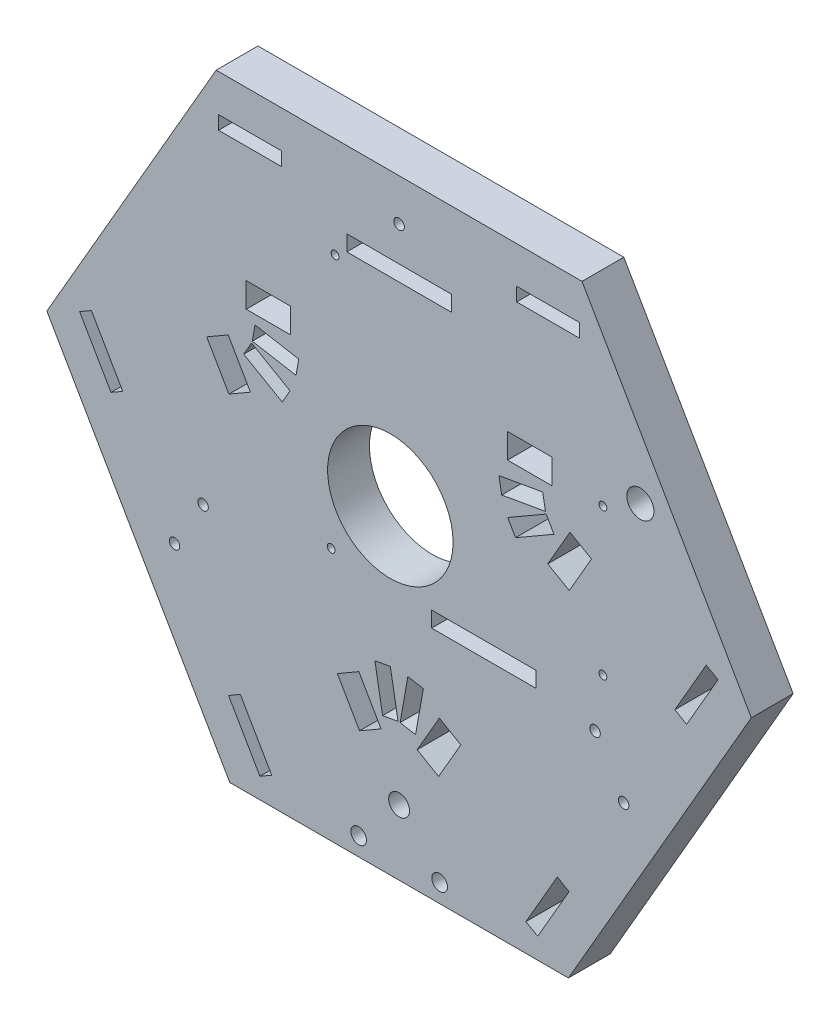
from build123d import *

# Parameters (mm, degrees)
ESBO_O2_R                = 2
ESBO_O2_R_2              = 1.5
ESBO_O2_R_3              = 1
ESBO_O2_R_4              = 0.75
ESBO_O2_R_5              = 2.6
ESBO_O2_R_6              = 12
ESBO_O2_W                = 12
ESBO_O2_H                = 2.6
ESBO_O2_W_2              = 8.5
ESBO_O2_H_2              = 4.75
ESBO_O2_W_3              = 20
ESBO_O2_H_3              = 3
RESSALTO_EXTRUS_O1_DEPTH = 8


with BuildPart() as part:
    # Esboço2 → Ressalto-extrusão1 (new body)
    with BuildSketch(Plane.XY):
        Polygon((312.401923789, 240.878221735), (347.401923789, 301.5), (315, 357.621778265), (245, 357.621778265), (212.598076211, 301.5), (247.598076211, 240.878221735), align=None)
        with Locations((280, 253.378221735)):
            Circle(ESBO_O2_R, mode=Mode.SUBTRACT)
        with Locations((272.260343171, 244.388972359)):
            Circle(ESBO_O2_R_2, mode=Mode.SUBTRACT)
        with Locations((287.760343171, 244.388972359)):
            Circle(ESBO_O2_R_2, mode=Mode.SUBTRACT)
        with Locations((242.5, 284.378221735)):
            Circle(ESBO_O2_R_3, mode=Mode.SUBTRACT)
        with Locations((317.5, 284.378221735)):
            Circle(ESBO_O2_R_3, mode=Mode.SUBTRACT)
        with Locations((267.750492284, 338.382369461)):
            Circle(ESBO_O2_R_4, mode=Mode.SUBTRACT)
        with Locations((267, 289.378221735)):
            Circle(ESBO_O2_R_4, mode=Mode.SUBTRACT)
        with Locations((319, 294.378221735)):
            Circle(ESBO_O2_R_4, mode=Mode.SUBTRACT)
        with Locations((319, 322.378221735)):
            Circle(ESBO_O2_R_4, mode=Mode.SUBTRACT)
        with Locations((280, 349.621778265)):
            Circle(ESBO_O2_R_3, mode=Mode.SUBTRACT)
        with Locations((237.026279442, 275.189110868)):
            Circle(ESBO_O2_R_3, mode=Mode.SUBTRACT)
        with Locations((322.973720558, 275.189110868)):
            Circle(ESBO_O2_R_3, mode=Mode.SUBTRACT)
        with Locations((326.159646677, 326.362840761)):
            Circle(ESBO_O2_R_5, mode=Mode.SUBTRACT)
        with Locations((278.32399049, 302.032244112)):
            Circle(ESBO_O2_R_6, mode=Mode.SUBTRACT)
        with Locations((251.453146627, 349.186651246)):
            Rectangle(ESBO_O2_W, ESBO_O2_H, mode=Mode.SUBTRACT)
        with Locations((308.5, 349.259600438)):
            Rectangle(ESBO_O2_W, ESBO_O2_H, mode=Mode.SUBTRACT)
        Polygon((332.76851184, 295.516364843), (335.020177889, 294.216364843), (341.020177889, 304.608669688), (338.76851184, 305.908669688), align=None, mode=Mode.SUBTRACT)
        Polygon((310.272092192, 256.543153732), (312.523758242, 255.243153732), (306.520177889, 244.852916827), (304.26851184, 246.152916827), align=None, mode=Mode.SUBTRACT)
        Polygon((255.623234985, 246.090416827), (253.371568935, 244.790416827), (247.371568935, 255.182721672), (249.623234985, 256.482721672), align=None, mode=Mode.SUBTRACT)
        Polygon((227.123234985, 295.453864843), (224.871568935, 294.153864843), (218.871568935, 304.546169688), (221.123234985, 305.846169688), align=None, mode=Mode.SUBTRACT)
        with Locations((305, 323.246778265)):
            Rectangle(ESBO_O2_W_2, ESBO_O2_H_2, mode=Mode.SUBTRACT)
        Polygon((312.7004902, 314.895353928), (308.4504902, 307.534137996), (312.564110868, 305.159137996), (316.814110868, 312.520353928), align=None, mode=Mode.SUBTRACT)
        with Locations((255, 323.246778265)):
            Rectangle(ESBO_O2_W_2, ESBO_O2_H_2, mode=Mode.SUBTRACT)
        Polygon((251.5495098, 307.534137996), (247.2995098, 314.895353928), (243.185889132, 312.520353928), (247.435889132, 305.159137996), align=None, mode=Mode.SUBTRACT)
        Polygon((272.2995098, 271.594083739), (268.185889132, 269.219083739), (272.435889132, 261.857867807), (276.5495098, 264.232867807), align=None, mode=Mode.SUBTRACT)
        Polygon((287.7004902, 271.594083739), (283.4504902, 264.232867807), (287.564110868, 261.857867807), (291.814110868, 269.219083739), align=None, mode=Mode.SUBTRACT)
        Polygon((279.8, 267.1), (278.32399049, 275.470865901), (275.369567231, 274.949921368), (276.845576741, 266.579055467), align=None, mode=Mode.SUBTRACT)
        Polygon((281.67600951, 275.470865901), (280.2, 267.1), (283.154423259, 266.579055467), (284.630432769, 274.949921368), align=None, mode=Mode.SUBTRACT)
        Polygon((308.136808057, 315.624122952), (300.775592125, 311.374122952), (302.275592125, 308.77604674), (309.636808057, 313.02604674), align=None, mode=Mode.SUBTRACT)
        Polygon((299.629134099, 314.52399049), (308, 316), (307.479055467, 318.954423259), (299.108189566, 317.478413749), align=None, mode=Mode.SUBTRACT)
        Polygon((251.907080103, 316.160436254), (260.277946003, 314.684426744), (260.798890536, 317.638850003), (252.428024636, 319.114859513), align=None, mode=Mode.SUBTRACT)
        Polygon((259.131487977, 311.534559206), (251.770272045, 315.784559206), (250.270272045, 313.186482994), (257.631487977, 308.936482994), align=None, mode=Mode.SUBTRACT)
        with Locations((280, 341.5)):
            Rectangle(ESBO_O2_W_3, ESBO_O2_H_3, mode=Mode.SUBTRACT)
        with Locations((296.230303561, 287.270994592)):
            Rectangle(ESBO_O2_W_3, ESBO_O2_H_3, mode=Mode.SUBTRACT)
    extrude(amount=RESSALTO_EXTRUS_O1_DEPTH)


solid = part.part
